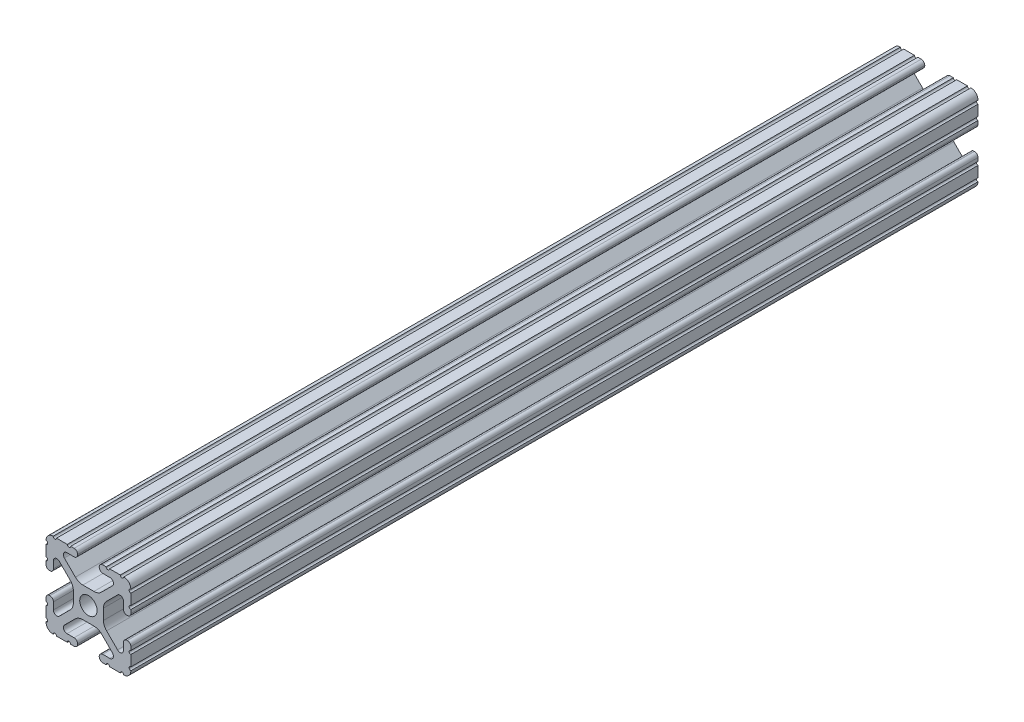
from build123d import *

# Parameters (mm, degrees)
SKETCH1_R               = 2.6035
BOSS_EXTRUDE1_DEPTH     = 304.8
SKETCH2_W               = 358.370469457
SKETCH2_H               = 29.886329236
CUT_EXTRUDE1_DEPTH      = 2.794
CUT_EXTRUDE1_DEPTH_BACK = 29.464


with BuildPart() as part:
    # Sketch1 → Boss-Extrude1 (new body, symmetric)
    with BuildSketch(Plane.XY):
        with BuildLine():
            Line((-7.179650497, -8.645192506), (-3.952270251, -5.423690499))
            ThreePointArc((-3.952270251, -5.423690499), (-2.922936451, -4.736929036), (-1.709253557, -4.4958))
            Line((-1.709253557, -4.4958), (1.709253557, -4.4958))
            ThreePointArc((1.709253557, -4.4958), (2.922936451, -4.736929036), (3.952270251, -5.423690499))
            Line((3.952270251, -5.423690499), (7.179650497, -8.645192506))
            ThreePointArc((7.179650497, -8.645192506), (7.41473083, -9.822813117), (6.416408329, -10.4902))
            Line((6.416408329, -10.4902), (4.287512407, -10.4902))
            ThreePointArc((4.287512407, -10.4902), (3.54574862, -10.79744862), (3.2385, -11.539212407))
            Line((3.2385, -11.539212407), (3.2385, -11.650987593))
            ThreePointArc((3.2385, -11.650987593), (3.54574862, -12.39275138), (4.287512407, -12.7))
            Line((4.287512407, -12.7), (5.317126718, -12.7))
            ThreePointArc((5.317126718, -12.7), (5.825126718, -12.192), (6.333126718, -12.7))
            Line((6.333126718, -12.7), (9.550443118, -12.7))
            ThreePointArc((9.550443118, -12.7), (10.058366869, -12.192000006), (10.566443095, -12.699847501))
            ThreePointArc((10.566443095, -12.699847501), (12.082537762, -12.08250727), (12.699846982, -10.566399977))
            ThreePointArc((12.699846982, -10.566399977), (12.192000006, -10.058323491), (12.7, -9.5504))
            Line((12.7, -9.5504), (12.7, -6.3330836))
            ThreePointArc((12.7, -6.3330836), (12.192, -5.8250836), (12.7, -5.3170836))
            Line((12.7, -5.3170836), (12.7, -4.287469289))
            ThreePointArc((12.7, -4.287469289), (12.39275138, -3.545705502), (11.650987593, -3.238456882))
            Line((11.650987593, -3.238456882), (11.539212407, -3.238456882))
            ThreePointArc((11.539212407, -3.238456882), (10.79744862, -3.545705502), (10.4902, -4.287469289))
            Line((10.4902, -4.287469289), (10.4902, -6.402089023))
            ThreePointArc((10.4902, -6.402089023), (9.856505071, -7.351067942), (8.737131347, -7.129408934))
            Line((8.737131347, -7.129408934), (5.441005833, -3.840816462))
            ThreePointArc((5.441005833, -3.840816462), (4.750877967, -2.809883091), (4.5085, -1.593185507))
            Line((4.5085, -1.593185507), (4.5085, 1.593185507))
            ThreePointArc((4.5085, 1.593185507), (4.750877967, 2.809883091), (5.441005833, 3.840816462))
            Line((5.441005833, 3.840816462), (8.737131347, 7.129408934))
            ThreePointArc((8.737131347, 7.129408934), (9.856505071, 7.351067942), (10.4902, 6.402089023))
            Line((10.4902, 6.402089023), (10.4902, 4.287469289))
            ThreePointArc((10.4902, 4.287469289), (10.79744862, 3.545705502), (11.539212407, 3.238456882))
            Line((11.539212407, 3.238456882), (11.650987593, 3.238456882))
            ThreePointArc((11.650987593, 3.238456882), (12.39275138, 3.545705502), (12.7, 4.287469289))
            Line((12.7, 4.287469289), (12.7, 5.3170836))
            ThreePointArc((12.7, 5.3170836), (12.192, 5.8250836), (12.7, 6.3330836))
            Line((12.7, 6.3330836), (12.7, 9.5504))
            ThreePointArc((12.7, 9.5504), (12.192000006, 10.058323491), (12.699846982, 10.566399977))
            ThreePointArc((12.699846982, 10.566399977), (12.082537762, 12.08250727), (10.566443095, 12.699847501))
            ThreePointArc((10.566443095, 12.699847501), (10.058366869, 12.192000006), (9.550443118, 12.7))
            Line((9.550443118, 12.7), (6.333126718, 12.7))
            ThreePointArc((6.333126718, 12.7), (5.825126718, 12.192), (5.317126718, 12.7))
            Line((5.317126718, 12.7), (4.287512407, 12.7))
            ThreePointArc((4.287512407, 12.7), (3.54574862, 12.39275138), (3.2385, 11.650987593))
            Line((3.2385, 11.650987593), (3.2385, 11.539212407))
            ThreePointArc((3.2385, 11.539212407), (3.54574862, 10.79744862), (4.287512407, 10.4902))
            Line((4.287512407, 10.4902), (6.476788598, 10.4902))
            ThreePointArc((6.476788598, 10.4902), (7.432222385, 9.85140422), (7.207036008, 8.724370562))
            Line((7.207036008, 8.724370562), (3.898272566, 5.423169045))
            ThreePointArc((3.898272566, 5.423169045), (2.869120213, 4.736787962), (1.655778399, 4.4958))
            Line((1.655778399, 4.4958), (-1.655778399, 4.4958))
            ThreePointArc((-1.655778399, 4.4958), (-2.869120213, 4.736787962), (-3.898272566, 5.423169045))
            Line((-3.898272566, 5.423169045), (-7.207036008, 8.724370562))
            ThreePointArc((-7.207036008, 8.724370562), (-7.432222385, 9.85140422), (-6.476788598, 10.4902))
            Line((-6.476788598, 10.4902), (-4.287512407, 10.4902))
            ThreePointArc((-4.287512407, 10.4902), (-3.54574862, 10.79744862), (-3.2385, 11.539212407))
            Line((-3.2385, 11.539212407), (-3.2385, 11.650987593))
            ThreePointArc((-3.2385, 11.650987593), (-3.54574862, 12.39275138), (-4.287512407, 12.7))
            Line((-4.287512407, 12.7), (-5.317126718, 12.7))
            ThreePointArc((-5.317126718, 12.7), (-5.825126718, 12.192), (-6.333126718, 12.7))
            Line((-6.333126718, 12.7), (-9.550443118, 12.7))
            ThreePointArc((-9.550443118, 12.7), (-10.058366869, 12.192000006), (-10.566443095, 12.699847501))
            ThreePointArc((-10.566443095, 12.699847501), (-12.082537762, 12.08250727), (-12.699846982, 10.566399977))
            ThreePointArc((-12.699846982, 10.566399977), (-12.192000006, 10.058323491), (-12.7, 9.5504))
            Line((-12.7, 9.5504), (-12.7, 6.3330836))
            ThreePointArc((-12.7, 6.3330836), (-12.192, 5.8250836), (-12.7, 5.3170836))
            Line((-12.7, 5.3170836), (-12.7, 4.287469289))
            ThreePointArc((-12.7, 4.287469289), (-12.39275138, 3.545705502), (-11.650987593, 3.238456882))
            Line((-11.650987593, 3.238456882), (-11.539212407, 3.238456882))
            ThreePointArc((-11.539212407, 3.238456882), (-10.79744862, 3.545705502), (-10.4902, 4.287469289))
            Line((-10.4902, 4.287469289), (-10.4902, 6.402089023))
            ThreePointArc((-10.4902, 6.402089023), (-9.856505071, 7.351067942), (-8.737131347, 7.129408934))
            Line((-8.737131347, 7.129408934), (-5.441005833, 3.840816462))
            ThreePointArc((-5.441005833, 3.840816462), (-4.750877967, 2.809883091), (-4.5085, 1.593185507))
            Line((-4.5085, 1.593185507), (-4.5085, -1.593185507))
            ThreePointArc((-4.5085, -1.593185507), (-4.750877967, -2.809883091), (-5.441005833, -3.840816462))
            Line((-5.441005833, -3.840816462), (-8.737131347, -7.129408934))
            ThreePointArc((-8.737131347, -7.129408934), (-9.856505071, -7.351067942), (-10.4902, -6.402089023))
            Line((-10.4902, -6.402089023), (-10.4902, -4.287469289))
            ThreePointArc((-10.4902, -4.287469289), (-10.79744862, -3.545705502), (-11.539212407, -3.238456882))
            Line((-11.539212407, -3.238456882), (-11.650987593, -3.238456882))
            ThreePointArc((-11.650987593, -3.238456882), (-12.39275138, -3.545705502), (-12.7, -4.287469289))
            Line((-12.7, -4.287469289), (-12.7, -5.3170836))
            ThreePointArc((-12.7, -5.3170836), (-12.192, -5.8250836), (-12.7, -6.3330836))
            Line((-12.7, -6.3330836), (-12.7, -9.5504))
            ThreePointArc((-12.7, -9.5504), (-12.192000006, -10.058323491), (-12.699846982, -10.566399977))
            ThreePointArc((-12.699846982, -10.566399977), (-12.082537762, -12.08250727), (-10.566443095, -12.699847501))
            ThreePointArc((-10.566443095, -12.699847501), (-10.058366869, -12.192000006), (-9.550443118, -12.7))
            Line((-9.550443118, -12.7), (-6.333126718, -12.7))
            ThreePointArc((-6.333126718, -12.7), (-5.825126718, -12.192), (-5.317126718, -12.7))
            Line((-5.317126718, -12.7), (-4.287512407, -12.7))
            ThreePointArc((-4.287512407, -12.7), (-3.54574862, -12.39275138), (-3.2385, -11.650987593))
            Line((-3.2385, -11.650987593), (-3.2385, -11.539212407))
            ThreePointArc((-3.2385, -11.539212407), (-3.54574862, -10.79744862), (-4.287512407, -10.4902))
            Line((-4.287512407, -10.4902), (-6.416408329, -10.4902))
            ThreePointArc((-6.416408329, -10.4902), (-7.41473083, -9.822813117), (-7.179650497, -8.645192506))
        make_face()
        Circle(SKETCH1_R, mode=Mode.SUBTRACT)
    extrude(amount=BOSS_EXTRUDE1_DEPTH, both=True)

    # Sketch2 → Cut-Extrude1 (cut, two sides)
    with BuildSketch(Plane.ZY.offset(12.7)) as cut_extrude1_sk:
        with Locations((128.022864135, 0.284213822)):
            Rectangle(SKETCH2_W, SKETCH2_H)
    extrude(amount=CUT_EXTRUDE1_DEPTH, mode=Mode.SUBTRACT)
    extrude(cut_extrude1_sk.sketch, amount=-CUT_EXTRUDE1_DEPTH_BACK, mode=Mode.SUBTRACT)


solid = part.part
